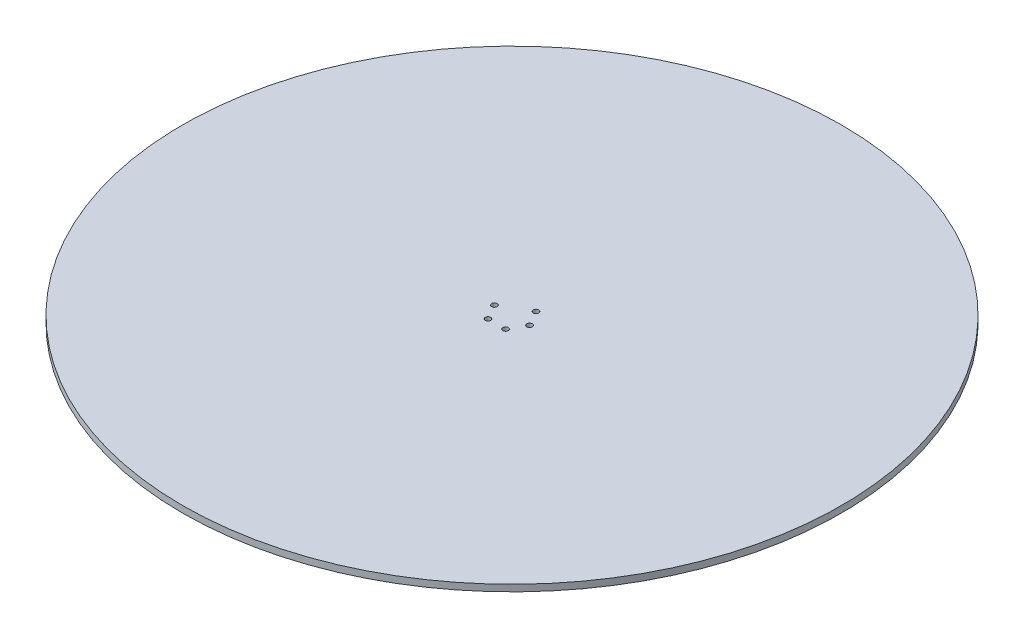
from build123d import *

# Parameters (mm, degrees)
SKETCH1_R           = 150
BOSS_EXTRUDE1_DEPTH = 3
SKETCH3_R           = 1.25
CUT_EXTRUDE1_DEPTH  = 10


with BuildPart() as part:
    # Sketch1 → Boss-Extrude1 (new body)
    with BuildSketch(Plane(origin=(0, 0, 0), x_dir=(1, 0, 0), z_dir=(0, 1, 0))):
        Circle(SKETCH1_R)
    extrude(amount=BOSS_EXTRUDE1_DEPTH)

    # Sketch3 → Cut-Extrude1 (cut)
    with BuildSketch(Plane.XZ):
        with Locations((8, 0)):
            Circle(SKETCH3_R)
        with Locations((4, 6.92820323)):
            Circle(SKETCH3_R)
        with Locations((4, -6.92820323)):
            Circle(SKETCH3_R)
        with Locations((-4, 6.92820323)):
            Circle(SKETCH3_R)
        with Locations((-8, 0)):
            Circle(SKETCH3_R)
    extrude(amount=-CUT_EXTRUDE1_DEPTH, mode=Mode.SUBTRACT)


solid = part.part
